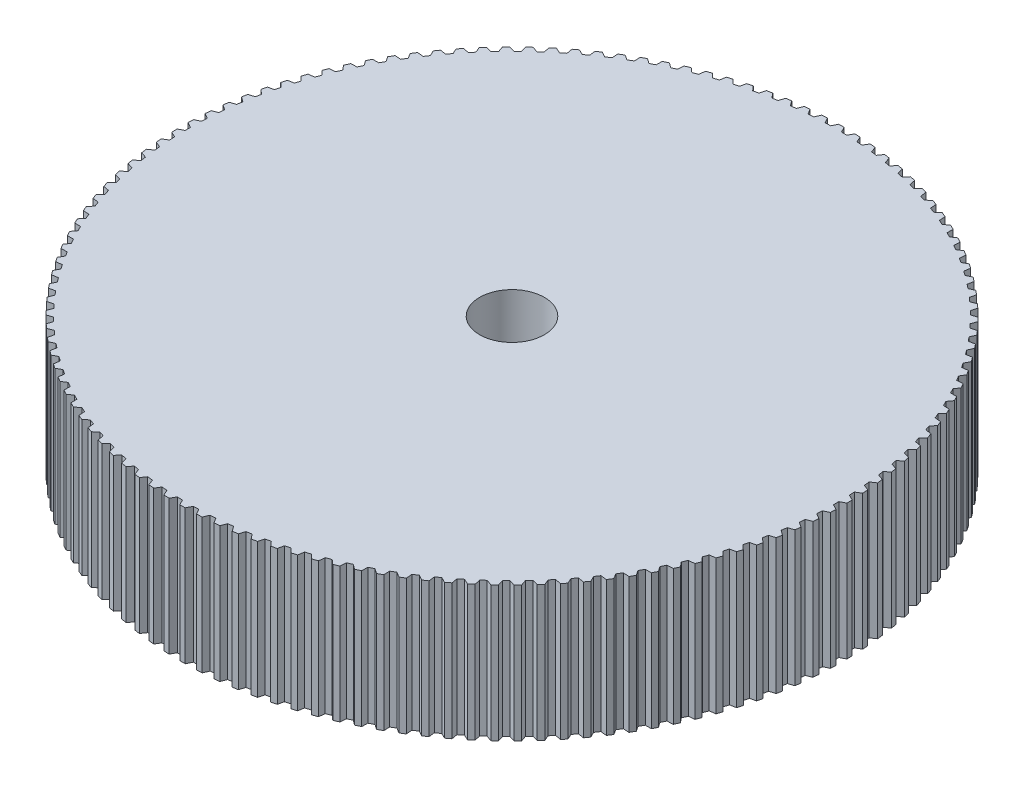
from build123d import *

# Parameters (mm, degrees)
BOSS_EXTRUDE3_DEPTH = 12.5
SKETCH4_R           = 3
CUT_EXTRUDE2_DEPTH  = 12.5


with BuildPart() as part:
    # Sketch3 → Boss-Extrude3 (new body)
    with BuildSketch(Plane(origin=(0, 0, 0), x_dir=(1, 0, 0), z_dir=(0, 1, 0))):
        Polygon((-0.25, 30.5), (0.25, 30.5), (0.5, 30), (0.995998109, 29.987630579), (1.270610282, 30.474547569), (1.769988743, 30.449624626), (1.99475503, 29.937784694), (2.48952001, 29.900707184), (2.788061627, 30.37333061), (3.285577015, 30.323546687), (3.484550786, 29.801139338), (3.976852572, 29.73944592), (4.298581412, 30.196600766), (4.792996825, 30.122079633), (4.965683398, 29.590403654), (5.454298052, 29.504247707), (5.798414246, 29.944797415), (6.28850049, 29.845724344), (6.43447054, 29.306101564), (6.918183288, 29.195697286), (7.283831308, 29.618546579), (7.768369951, 29.495167881), (7.887260574, 28.948939888), (8.364868829, 28.814561761), (8.751139618, 29.21865937), (9.228926021, 29.071281783), (9.320441635, 28.519806586), (9.790757989, 28.361788695), (10.196691216, 28.74612997), (10.666537527, 28.575119898), (10.73045061, 28.019768552), (11.192305782, 27.838503754), (11.616892233, 28.202133161), (12.077630339, 28.007915763), (12.113781994, 27.450068958), (12.56602774, 27.246007907), (13.008211826, 27.588021406), (13.45869626, 27.371079536), (13.466996607, 26.812124168), (13.908508572, 26.58577419), (14.367190955, 26.905321482), (14.806301741, 26.666194493), (14.786730145, 26.107520212), (15.216410661, 25.859444051), (15.690450983, 26.155730691), (16.117096423, 25.895013089), (16.069701542, 25.338008847), (16.486482355, 25.068823259), (16.974702077, 25.341112631), (17.387821465, 25.059452602), (17.312721129, 24.5055032), (17.715566056, 24.215877422), (18.216751388, 24.463492573), (18.615317642, 24.161590368), (18.512698563, 23.612073012), (18.900606069, 23.302727098), (19.413510985, 23.525052418), (19.796533206, 23.203658613), (19.666650512, 22.659939489), (20.038656197, 22.331642524), (20.562005534, 22.528125275), (20.92853147, 22.188038906), (20.771708069, 21.651469786), (21.126887069, 21.305037967), (21.659379698, 21.475189664), (22.008498107, 21.117256239), (21.825123887, 20.589171118), (22.16259317, 20.225465729), (22.702905231, 20.368863347), (23.03374815, 19.993972746), (22.824279008, 19.475684526), (23.143199573, 19.095609797), (23.689987765, 19.211896827), (24.001732666, 18.820981086), (23.766689375, 18.313778315), (24.066268335, 17.91827917), (24.618173256, 18.007166505), (24.910045092, 17.601197502), (24.650012008, 17.106341164), (24.929504563, 16.696400878), (25.48515409, 16.757667529), (25.756427222, 16.337654567), (25.472050826, 15.856374954), (25.730762114, 15.433012702), (26.288774815, 15.466506351), (26.538774815, 15.033493649), (26.230762114, 14.566987298), (26.468048936, 14.131255625), (27.027037504, 14.136893001), (27.255142833, 13.691957097), (26.924259593, 13.241383816), (27.139532018, 12.79436602), (27.69810672, 12.772133109), (27.903750271, 12.316380182), (27.550819121, 11.882860168), (27.743541947, 11.425667605), (28.300314078, 11.37561968), (28.48298459, 10.910182806), (28.108882972, 10.494793857), (28.27857706, 10.028563181), (28.832162396, 9.950824669), (28.991405721, 9.476860996), (28.59706371, 9.080635834), (28.743307174, 8.606526168), (29.292329415, 8.50129034), (29.427749649, 8.019978217), (29.014147643, 7.643901921), (29.136576898, 7.163091975), (29.679671088, 7.030620464), (29.790931555, 6.543156508), (29.359097832, 6.188164063), (29.457408502, 5.701849207), (29.993224422, 5.542471357), (30.080048511, 5.050067481), (29.631056679, 4.717041454), (29.705004346, 4.226430743), (30.232209875, 4.040542793), (30.294381727, 3.54442319), (29.82934805, 3.234191536), (29.878748869, 2.740504706), (30.396033291, 2.528568804), (30.433398337, 2.029966905), (29.953478962, 1.743300909), (29.978210114, 1.247765343), (30.484287378, 1.010308394), (30.496752724, 0.510463803), (30.003140806, 0.248076161), (30.003140806, -0.248076161), (30.496752724, -0.510463803), (30.484287378, -1.010308394), (29.978210114, -1.247765343), (29.953478962, -1.743300909), (30.433398337, -2.029966905), (30.396033291, -2.528568804), (29.878748869, -2.740504706), (29.82934805, -3.234191536), (30.294381727, -3.54442319), (30.232209875, -4.040542793), (29.705004346, -4.226430743), (29.631056679, -4.717041454), (30.080048511, -5.050067481), (29.993224422, -5.542471357), (29.457408502, -5.701849207), (29.359097832, -6.188164063), (29.790931555, -6.543156508), (29.679671088, -7.030620464), (29.136576898, -7.163091975), (29.014147643, -7.643901921), (29.427749649, -8.019978217), (29.292329415, -8.50129034), (28.743307174, -8.606526168), (28.59706371, -9.080635834), (28.991405721, -9.476860996), (28.832162396, -9.950824669), (28.27857706, -10.028563181), (28.108882972, -10.494793857), (28.48298459, -10.910182806), (28.300314078, -11.37561968), (27.743541947, -11.425667605), (27.550819121, -11.882860168), (27.903750271, -12.316380182), (27.69810672, -12.772133109), (27.139532018, -12.79436602), (26.924259593, -13.241383816), (27.255142833, -13.691957097), (27.027037504, -14.136893001), (26.468048936, -14.131255625), (26.230762114, -14.566987298), (26.538774815, -15.033493649), (26.288774815, -15.466506351), (25.730762114, -15.433012702), (25.472050826, -15.856374954), (25.756427222, -16.337654567), (25.48515409, -16.757667529), (24.929504563, -16.696400878), (24.650012008, -17.106341164), (24.910045092, -17.601197502), (24.618173256, -18.007166505), (24.066268335, -17.91827917), (23.766689375, -18.313778315), (24.001732666, -18.820981086), (23.689987765, -19.211896827), (23.143199573, -19.095609797), (22.824279008, -19.475684526), (23.03374815, -19.993972746), (22.702905231, -20.368863347), (22.16259317, -20.225465729), (21.825123887, -20.589171118), (22.008498107, -21.117256239), (21.659379698, -21.475189664), (21.126887069, -21.305037967), (20.771708069, -21.651469786), (20.92853147, -22.188038906), (20.562005534, -22.528125275), (20.038656197, -22.331642524), (19.666650512, -22.659939489), (19.796533206, -23.203658613), (19.413510985, -23.525052418), (18.900606069, -23.302727098), (18.512698563, -23.612073012), (18.615317642, -24.161590368), (18.216751388, -24.463492573), (17.715566056, -24.215877422), (17.312721129, -24.5055032), (17.387821465, -25.059452602), (16.974702077, -25.341112631), (16.486482355, -25.068823259), (16.069701542, -25.338008847), (16.117096423, -25.895013089), (15.690450983, -26.155730691), (15.216410661, -25.859444051), (14.786730145, -26.107520212), (14.806301741, -26.666194493), (14.367190955, -26.905321482), (13.908508572, -26.58577419), (13.466996607, -26.812124168), (13.45869626, -27.371079536), (13.008211826, -27.588021406), (12.56602774, -27.246007907), (12.113781994, -27.450068958), (12.077630339, -28.007915763), (11.616892233, -28.202133161), (11.192305782, -27.838503754), (10.73045061, -28.019768552), (10.666537527, -28.575119898), (10.196691216, -28.74612997), (9.790757989, -28.361788695), (9.320441635, -28.519806586), (9.228926021, -29.071281783), (8.751139618, -29.21865937), (8.364868829, -28.814561761), (7.887260574, -28.948939888), (7.768369951, -29.495167881), (7.283831308, -29.618546579), (6.918183288, -29.195697286), (6.43447054, -29.306101564), (6.28850049, -29.845724344), (5.798414246, -29.944797415), (5.454298052, -29.504247707), (4.965683398, -29.590403654), (4.792996825, -30.122079633), (4.298581412, -30.196600766), (3.976852572, -29.73944592), (3.484550786, -29.801139338), (3.285577015, -30.323546687), (2.788061627, -30.37333061), (2.48952001, -29.900707184), (1.99475503, -29.937784694), (1.769988743, -30.449624626), (1.270610282, -30.474547569), (0.995998109, -29.987630579), (0.5, -30), (0.25, -30.5), (-0.25, -30.5), (-0.5, -30), (-0.995998109, -29.987630579), (-1.270610282, -30.474547569), (-1.769988743, -30.449624626), (-1.99475503, -29.937784694), (-2.48952001, -29.900707184), (-2.788061627, -30.37333061), (-3.285577015, -30.323546687), (-3.484550786, -29.801139338), (-3.976852572, -29.73944592), (-4.298581412, -30.196600766), (-4.792996825, -30.122079633), (-4.965683398, -29.590403654), (-5.454298052, -29.504247707), (-5.798414246, -29.944797415), (-6.28850049, -29.845724344), (-6.43447054, -29.306101564), (-6.918183288, -29.195697286), (-7.283831308, -29.618546579), (-7.768369951, -29.495167881), (-7.887260574, -28.948939888), (-8.364868829, -28.814561761), (-8.751139618, -29.21865937), (-9.228926021, -29.071281783), (-9.320441635, -28.519806586), (-9.790757989, -28.361788695), (-10.196691216, -28.74612997), (-10.666537527, -28.575119898), (-10.73045061, -28.019768552), (-11.192305782, -27.838503754), (-11.616892233, -28.202133161), (-12.077630339, -28.007915763), (-12.113781994, -27.450068958), (-12.56602774, -27.246007907), (-13.008211826, -27.588021406), (-13.45869626, -27.371079536), (-13.466996607, -26.812124168), (-13.908508572, -26.58577419), (-14.367190955, -26.905321482), (-14.806301741, -26.666194493), (-14.786730145, -26.107520212), (-15.216410661, -25.859444051), (-15.690450983, -26.155730691), (-16.117096423, -25.895013089), (-16.069701542, -25.338008847), (-16.486482355, -25.068823259), (-16.974702077, -25.341112631), (-17.387821465, -25.059452602), (-17.312721129, -24.5055032), (-17.715566056, -24.215877422), (-18.216751388, -24.463492573), (-18.615317642, -24.161590368), (-18.512698563, -23.612073012), (-18.900606069, -23.302727098), (-19.413510985, -23.525052418), (-19.796533206, -23.203658613), (-19.666650512, -22.659939489), (-20.038656197, -22.331642524), (-20.562005534, -22.528125275), (-20.92853147, -22.188038906), (-20.771708069, -21.651469786), (-21.126887069, -21.305037967), (-21.659379698, -21.475189664), (-22.008498107, -21.117256239), (-21.825123887, -20.589171118), (-22.16259317, -20.225465729), (-22.702905231, -20.368863347), (-23.03374815, -19.993972746), (-22.824279008, -19.475684526), (-23.143199573, -19.095609797), (-23.689987765, -19.211896827), (-24.001732666, -18.820981086), (-23.766689375, -18.313778315), (-24.066268335, -17.91827917), (-24.618173256, -18.007166505), (-24.910045092, -17.601197502), (-24.650012008, -17.106341164), (-24.929504563, -16.696400878), (-25.48515409, -16.757667529), (-25.756427222, -16.337654567), (-25.472050826, -15.856374954), (-25.730762114, -15.433012702), (-26.288774815, -15.466506351), (-26.538774815, -15.033493649), (-26.230762114, -14.566987298), (-26.468048936, -14.131255625), (-27.027037504, -14.136893001), (-27.255142833, -13.691957097), (-26.924259593, -13.241383816), (-27.139532018, -12.79436602), (-27.69810672, -12.772133109), (-27.903750271, -12.316380182), (-27.550819121, -11.882860168), (-27.743541947, -11.425667605), (-28.300314078, -11.37561968), (-28.48298459, -10.910182806), (-28.108882972, -10.494793857), (-28.27857706, -10.028563181), (-28.832162396, -9.950824669), (-28.991405721, -9.476860996), (-28.59706371, -9.080635834), (-28.743307174, -8.606526168), (-29.292329415, -8.50129034), (-29.427749649, -8.019978217), (-29.014147643, -7.643901921), (-29.136576898, -7.163091975), (-29.679671088, -7.030620464), (-29.790931555, -6.543156508), (-29.359097832, -6.188164063), (-29.457408502, -5.701849207), (-29.993224422, -5.542471357), (-30.080048511, -5.050067481), (-29.631056679, -4.717041454), (-29.705004346, -4.226430743), (-30.232209875, -4.040542793), (-30.294381727, -3.54442319), (-29.82934805, -3.234191536), (-29.878748869, -2.740504706), (-30.396033291, -2.528568804), (-30.433398337, -2.029966905), (-29.953478962, -1.743300909), (-29.978210114, -1.247765343), (-30.484287378, -1.010308394), (-30.496752724, -0.510463803), (-30.003140806, -0.248076161), (-30.003140806, 0.248076161), (-30.496752724, 0.510463803), (-30.484287378, 1.010308394), (-29.978210114, 1.247765343), (-29.953478962, 1.743300909), (-30.433398337, 2.029966905), (-30.396033291, 2.528568804), (-29.878748869, 2.740504706), (-29.82934805, 3.234191536), (-30.294381727, 3.54442319), (-30.232209875, 4.040542793), (-29.705004346, 4.226430743), (-29.631056679, 4.717041454), (-30.080048511, 5.050067481), (-29.993224422, 5.542471357), (-29.457408502, 5.701849207), (-29.359097832, 6.188164063), (-29.790931555, 6.543156508), (-29.679671088, 7.030620464), (-29.136576898, 7.163091975), (-29.014147643, 7.643901921), (-29.427749649, 8.019978217), (-29.292329415, 8.50129034), (-28.743307174, 8.606526168), (-28.59706371, 9.080635834), (-28.991405721, 9.476860996), (-28.832162396, 9.950824669), (-28.27857706, 10.028563181), (-28.108882972, 10.494793857), (-28.48298459, 10.910182806), (-28.300314078, 11.37561968), (-27.743541947, 11.425667605), (-27.550819121, 11.882860168), (-27.903750271, 12.316380182), (-27.69810672, 12.772133109), (-27.139532018, 12.79436602), (-26.924259593, 13.241383816), (-27.255142833, 13.691957097), (-27.027037504, 14.136893001), (-26.468048936, 14.131255625), (-26.230762114, 14.566987298), (-26.538774815, 15.033493649), (-26.288774815, 15.466506351), (-25.730762114, 15.433012702), (-25.472050826, 15.856374954), (-25.756427222, 16.337654567), (-25.48515409, 16.757667529), (-24.929504563, 16.696400878), (-24.650012008, 17.106341164), (-24.910045092, 17.601197502), (-24.618173256, 18.007166505), (-24.066268335, 17.91827917), (-23.766689375, 18.313778315), (-24.001732666, 18.820981086), (-23.689987765, 19.211896827), (-23.143199573, 19.095609797), (-22.824279008, 19.475684526), (-23.03374815, 19.993972746), (-22.702905231, 20.368863347), (-22.16259317, 20.225465729), (-21.825123887, 20.589171118), (-22.008498107, 21.117256239), (-21.659379698, 21.475189664), (-21.126887069, 21.305037967), (-20.771708069, 21.651469786), (-20.92853147, 22.188038906), (-20.562005534, 22.528125275), (-20.038656197, 22.331642524), (-19.666650512, 22.659939489), (-19.796533206, 23.203658613), (-19.413510985, 23.525052418), (-18.900606069, 23.302727098), (-18.512698563, 23.612073012), (-18.615317642, 24.161590368), (-18.216751388, 24.463492573), (-17.715566056, 24.215877422), (-17.312721129, 24.5055032), (-17.387821465, 25.059452602), (-16.974702077, 25.341112631), (-16.486482355, 25.068823259), (-16.069701542, 25.338008847), (-16.117096423, 25.895013089), (-15.690450983, 26.155730691), (-15.216410661, 25.859444051), (-14.786730145, 26.107520212), (-14.806301741, 26.666194493), (-14.367190955, 26.905321482), (-13.908508572, 26.58577419), (-13.466996607, 26.812124168), (-13.45869626, 27.371079536), (-13.008211826, 27.588021406), (-12.56602774, 27.246007907), (-12.113781994, 27.450068958), (-12.077630339, 28.007915763), (-11.616892233, 28.202133161), (-11.192305782, 27.838503754), (-10.73045061, 28.019768552), (-10.666537527, 28.575119898), (-10.196691216, 28.74612997), (-9.790757989, 28.361788695), (-9.320441635, 28.519806586), (-9.228926021, 29.071281783), (-8.751139618, 29.21865937), (-8.364868829, 28.814561761), (-7.887260574, 28.948939888), (-7.768369951, 29.495167881), (-7.283831308, 29.618546579), (-6.918183288, 29.195697286), (-6.43447054, 29.306101564), (-6.28850049, 29.845724344), (-5.798414246, 29.944797415), (-5.454298052, 29.504247707), (-4.965683398, 29.590403654), (-4.792996825, 30.122079633), (-4.298581412, 30.196600766), (-3.976852572, 29.73944592), (-3.484550786, 29.801139338), (-3.285577015, 30.323546687), (-2.788061627, 30.37333061), (-2.48952001, 29.900707184), (-1.99475503, 29.937784694), (-1.769988743, 30.449624626), (-1.270610282, 30.474547569), (-0.995998109, 29.987630579), (-0.5, 30), align=None)
    extrude(amount=BOSS_EXTRUDE3_DEPTH)

    # Sketch4 → Cut-Extrude2 (cut)
    with BuildSketch(Plane(origin=(0, 0, 0), x_dir=(1, 0, 0), z_dir=(0, 1, 0))):
        Circle(SKETCH4_R)
    extrude(amount=CUT_EXTRUDE2_DEPTH, mode=Mode.SUBTRACT)


solid = part.part
